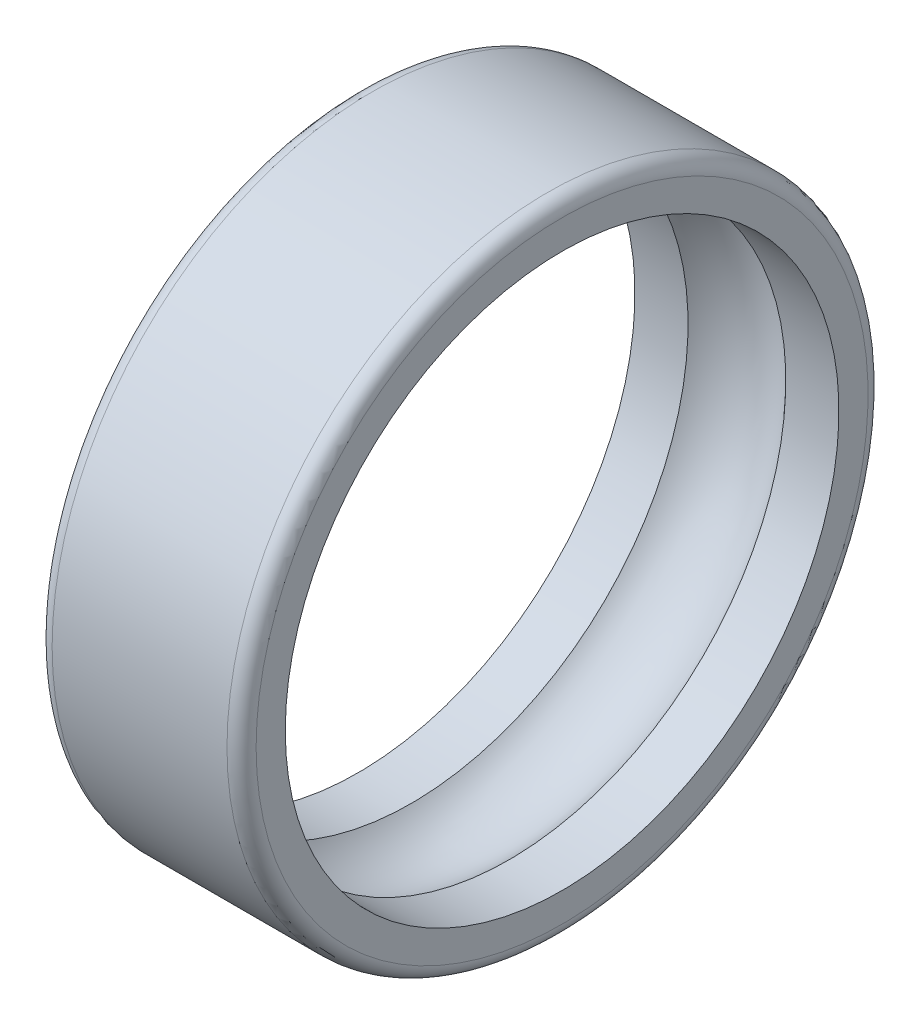
from build123d import *

# Parameters (mm, degrees)
FILLET1_R = 0.5


with BuildPart() as part:
    # Sketch1 → Revolve1 (revolve)
    with BuildSketch(Plane.XY):
        with BuildLine():
            Line((-3.5, 9.5), (-1.677050983, 9.5))
            ThreePointArc((-1.677050983, 9.5), (0, 10.25), (1.677050983, 9.5))
            Line((1.677050983, 9.5), (3.5, 9.5))
            Line((3.5, 9.5), (3.5, 11))
            Line((3.5, 11), (-3.5, 11))
            Line((-3.5, 11), (-3.5, 9.5))
        make_face()
    revolve(axis=Axis((-29.842592593, 0, 0), (1, 0, 0)))

    # Fillet1
    fillet1_edges = [part.edges().sort_by_distance(p)[0] for p in [
        (3.5, -11, 0),
        (-3.5, -11, 0),
    ]]
    fillet(fillet1_edges, radius=FILLET1_R)


solid = part.part
